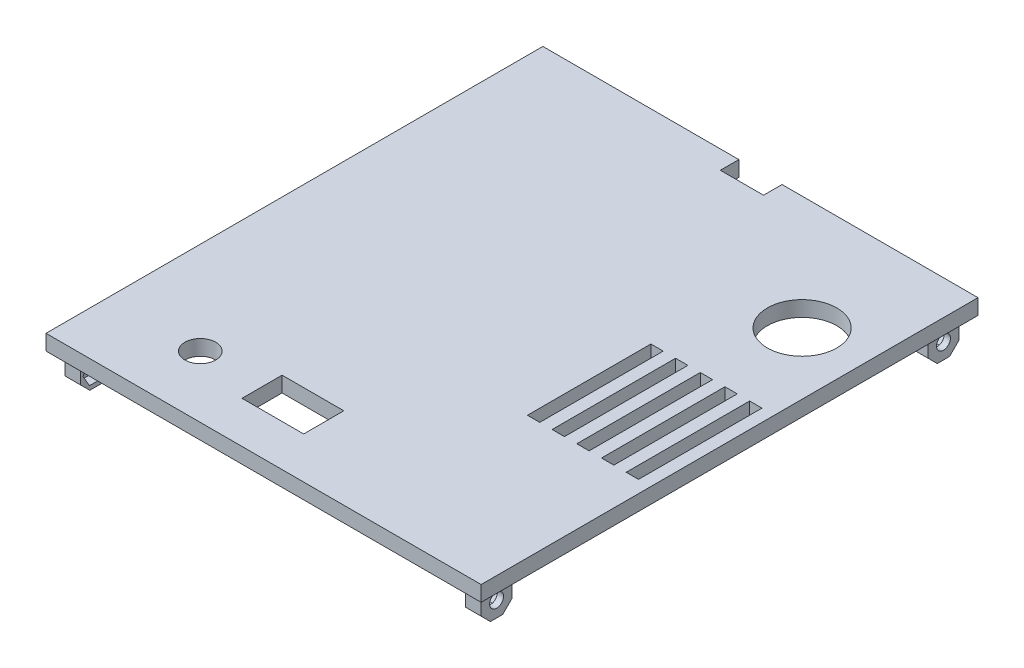
from build123d import *

# Parameters (mm, degrees)
SKETCH1_W                      = 141
SKETCH1_H                      = 161
BOSS_EXTRUDE1_DEPTH            = 5
CUT_EXTRUDE1_REACH             = 7
SKETCH2_R                      = 11.25
CUT_EXTRUDE1_DIRECTION_2_DEPTH = 1
CUT_EXTRUDE2_REACH             = 7
SKETCH3_W                      = 4
SKETCH3_H                      = 40
SKETCH4_W                      = 5
SKETCH4_H                      = 10
BOSS_EXTRUDE2_DEPTH            = 10
SKETCH5_R                      = 2.25
CUT_EXTRUDE3_DEPTH             = 4.1
CUT_EXTRUDE3_DEPTH_BACK        = 138.9
CUT_EXTRUDE4_DEPTH             = 3
CHAMFER1_SIZE                  = 3
MIRROR4_COPY_1_DEPTH           = 3
CUT_EXTRUDE5_REACH             = 17
SKETCH7_R                      = 5
SKETCH7_W                      = 20
SKETCH7_H                      = 13
CUT_EXTRUDE5_DIRECTION_2_DEPTH = 1
SKETCH8_W                      = 3.5
SKETCH8_H                      = 1
CUT_EXTRUDE6_DEPTH             = 11
CUT_EXTRUDE6_DEPTH_BACK        = 4
CUT_EXTRUDE7_REACH             = 17
SKETCH9_W                      = 14
SKETCH9_H                      = 6
CUT_EXTRUDE7_DIRECTION_2_DEPTH = 1


with BuildPart() as part:
    # Sketch1 → Boss-Extrude1 (new body)
    with BuildSketch(Plane(origin=(0, 0, 0), x_dir=(1, 0, 0), z_dir=(0, 1, 0))):
        Rectangle(SKETCH1_W, SKETCH1_H)
    extrude(amount=BOSS_EXTRUDE1_DEPTH)

    # Sketch2 → Cut-Extrude1 (cut, up to next)
    with BuildSketch(Plane(origin=(0, 5, 0), x_dir=(1, 0, 0), z_dir=(0, 1, 0)), mode=Mode.PRIVATE) as cut_extrude1_sk1:
        with Locations((50.5, 43.5)):
            Circle(SKETCH2_R)
    cut_extrude1_tool1 = extrude(cut_extrude1_sk1.sketch, amount=-CUT_EXTRUDE1_REACH, mode=Mode.PRIVATE) & part.part
    add(cut_extrude1_tool1.solids().sort_by_distance((50.5, 5, -43.5))[0], mode=Mode.SUBTRACT)

    # Sketch2 → Cut-Extrude1 direction 2 (cut)
    with BuildSketch(Plane(origin=(0, 5, 0), x_dir=(1, 0, 0), z_dir=(0, 1, 0))):
        with Locations((50.5, 43.5)):
            Circle(SKETCH2_R)
    extrude(amount=CUT_EXTRUDE1_DIRECTION_2_DEPTH, mode=Mode.SUBTRACT)

    # Sketch3 → Cut-Extrude2 (cut, up to next)
    with BuildSketch(Plane(origin=(0, 5, 0), x_dir=(1, 0, 0), z_dir=(0, 1, 0)), mode=Mode.PRIVATE) as cut_extrude2_sk1:
        with Locations((40.5, -5.5)):
            Rectangle(SKETCH3_W, SKETCH3_H)
    cut_extrude2_tool1 = extrude(cut_extrude2_sk1.sketch, amount=-CUT_EXTRUDE2_REACH, mode=Mode.PRIVATE) & part.part
    add(cut_extrude2_tool1.solids().sort_by_distance((40.5, 5, 5.5))[0], mode=Mode.SUBTRACT)
    # Sketch3 → Cut-Extrude2 (cut, up to next)
    with BuildSketch(Plane(origin=(0, 5, 0), x_dir=(1, 0, 0), z_dir=(0, 1, 0)), mode=Mode.PRIVATE) as cut_extrude2_sk2:
        with Locations((32.5, -5.5)):
            Rectangle(SKETCH3_W, SKETCH3_H)
    cut_extrude2_tool2 = extrude(cut_extrude2_sk2.sketch, amount=-CUT_EXTRUDE2_REACH, mode=Mode.PRIVATE) & part.part
    add(cut_extrude2_tool2.solids().sort_by_distance((32.5, 5, 5.5))[0], mode=Mode.SUBTRACT)
    # Sketch3 → Cut-Extrude2 (cut, up to next)
    with BuildSketch(Plane(origin=(0, 5, 0), x_dir=(1, 0, 0), z_dir=(0, 1, 0)), mode=Mode.PRIVATE) as cut_extrude2_sk3:
        with Locations((48.5, -5.5)):
            Rectangle(SKETCH3_W, SKETCH3_H)
    cut_extrude2_tool3 = extrude(cut_extrude2_sk3.sketch, amount=-CUT_EXTRUDE2_REACH, mode=Mode.PRIVATE) & part.part
    add(cut_extrude2_tool3.solids().sort_by_distance((48.5, 5, 5.5))[0], mode=Mode.SUBTRACT)
    # Sketch3 → Cut-Extrude2 (cut, up to next)
    with BuildSketch(Plane(origin=(0, 5, 0), x_dir=(1, 0, 0), z_dir=(0, 1, 0)), mode=Mode.PRIVATE) as cut_extrude2_sk4:
        with Locations((56.5, -5.5)):
            Rectangle(SKETCH3_W, SKETCH3_H)
    cut_extrude2_tool4 = extrude(cut_extrude2_sk4.sketch, amount=-CUT_EXTRUDE2_REACH, mode=Mode.PRIVATE) & part.part
    add(cut_extrude2_tool4.solids().sort_by_distance((56.5, 5, 5.5))[0], mode=Mode.SUBTRACT)
    # Sketch3 → Cut-Extrude2 (cut, up to next)
    with BuildSketch(Plane(origin=(0, 5, 0), x_dir=(1, 0, 0), z_dir=(0, 1, 0)), mode=Mode.PRIVATE) as cut_extrude2_sk5:
        with Locations((64.5, -5.5)):
            Rectangle(SKETCH3_W, SKETCH3_H)
    cut_extrude2_tool5 = extrude(cut_extrude2_sk5.sketch, amount=-CUT_EXTRUDE2_REACH, mode=Mode.PRIVATE) & part.part
    add(cut_extrude2_tool5.solids().sort_by_distance((64.5, 5, 5.5))[0], mode=Mode.SUBTRACT)

    # Sketch4 → Boss-Extrude2 (add)
    with BuildSketch(Plane.XZ):
        with Locations((64.9, 72.4)):
            Rectangle(SKETCH4_W, SKETCH4_H)
        with Locations((-64.9, 72.4)):
            Rectangle(SKETCH4_W, SKETCH4_H)
        with Locations((64.9, -72.4)):
            Rectangle(SKETCH4_W, SKETCH4_H)
        with Locations((-64.9, -72.4)):
            Rectangle(SKETCH4_W, SKETCH4_H)
    extrude(amount=BOSS_EXTRUDE2_DEPTH)

    # Sketch5 → Cut-Extrude3 (cut, two sides)
    with BuildSketch(Plane(origin=(67.4, 0, 0), x_dir=(0, 0, -1), z_dir=(1, 0, 0))) as cut_extrude3_sk:
        with Locations((-72.4, -5)):
            Circle(SKETCH5_R)
        with Locations((72.4, -5)):
            Circle(SKETCH5_R)
    extrude(amount=CUT_EXTRUDE3_DEPTH, mode=Mode.SUBTRACT)
    extrude(cut_extrude3_sk.sketch, amount=-CUT_EXTRUDE3_DEPTH_BACK, mode=Mode.SUBTRACT)

    # Sketch6 → Cut-Extrude4 (cut)
    with BuildSketch(Plane(origin=(-62.4, 0, 0), x_dir=(0, 0, -1), z_dir=(1, 0, 0))):
        Polygon((-68.185343035, -5), (-70.292671517, -1.35), (-74.507328483, -1.35), (-76.614656965, -5), (-74.507328483, -8.65), (-70.292671517, -8.65), align=None)
    cut_extrude4 = extrude(amount=-CUT_EXTRUDE4_DEPTH, mode=Mode.SUBTRACT)

    # Chamfer1
    chamfer1_edges = [part.edges().sort_by_distance(p)[0] for p in [
        (-64.9, -10, 77.4),
        (-64.9, -10, 67.4),
        (64.9, -10, -77.4),
        (64.9, -10, -67.4),
        (-64.9, -10, -77.4),
        (-64.9, -10, -67.4),
        (64.9, -10, 67.4),
        (64.9, -10, 77.4),
    ]]
    chamfer(chamfer1_edges, length=CHAMFER1_SIZE)

    # Mirror3: Cut-Extrude4 across plane
    add(cut_extrude4.mirror(Plane(origin=(0, 0, 0), x_dir=(0, 0, 1), z_dir=(1, 0, 0))), mode=Mode.SUBTRACT)

    # Mirror4: Cut-Extrude4 across plane
    add(cut_extrude4.mirror(Plane.XY), mode=Mode.SUBTRACT)

    # Mirror4 copy 1 sketch → Mirror4 copy 1 (cut)
    with BuildSketch(Plane.ZY.offset(-62.4)):
        Polygon((-68.185343035, -5), (-70.292671517, -1.35), (-74.507328483, -1.35), (-76.614656965, -5), (-74.507328483, -8.65), (-70.292671517, -8.65), align=None)
    extrude(amount=-MIRROR4_COPY_1_DEPTH, mode=Mode.SUBTRACT)

    # Sketch7 → Cut-Extrude5 (cut, up to next)
    with BuildSketch(Plane(origin=(0, 5, 0), x_dir=(1, 0, 0), z_dir=(0, 1, 0)), mode=Mode.PRIVATE) as cut_extrude5_sk1:
        with Locations((-40.5, -60.5)):
            Circle(SKETCH7_R)
    cut_extrude5_tool1 = extrude(cut_extrude5_sk1.sketch, amount=-CUT_EXTRUDE5_REACH, mode=Mode.PRIVATE) & part.part
    add(cut_extrude5_tool1.solids().sort_by_distance((-40.5, 5, 60.5))[0], mode=Mode.SUBTRACT)
    # Sketch7 → Cut-Extrude5 (cut, up to next)
    with BuildSketch(Plane(origin=(0, 5, 0), x_dir=(1, 0, 0), z_dir=(0, 1, 0)), mode=Mode.PRIVATE) as cut_extrude5_sk2:
        with Locations((-10.5, -60.5)):
            Rectangle(SKETCH7_W, SKETCH7_H)
    cut_extrude5_tool2 = extrude(cut_extrude5_sk2.sketch, amount=-CUT_EXTRUDE5_REACH, mode=Mode.PRIVATE) & part.part
    add(cut_extrude5_tool2.solids().sort_by_distance((-10.5, 5, 60.5))[0], mode=Mode.SUBTRACT)

    # Sketch7 → Cut-Extrude5 direction 2 (cut)
    with BuildSketch(Plane(origin=(0, 5, 0), x_dir=(1, 0, 0), z_dir=(0, 1, 0))):
        with Locations((-40.5, -60.5)):
            Circle(SKETCH7_R)
        with Locations((-10.5, -60.5)):
            Rectangle(SKETCH7_W, SKETCH7_H)
    extrude(amount=CUT_EXTRUDE5_DIRECTION_2_DEPTH, mode=Mode.SUBTRACT)

    # Sketch8 → Cut-Extrude6 (cut, two sides)
    with BuildSketch(Plane.XZ) as cut_extrude6_sk:
        with Locations((-40.5, 74)):
            Rectangle(SKETCH8_W, SKETCH8_H)
        with Locations((-40.5, 47)):
            Rectangle(SKETCH8_W, SKETCH8_H)
    extrude(amount=CUT_EXTRUDE6_DEPTH, mode=Mode.SUBTRACT)
    extrude(cut_extrude6_sk.sketch, amount=-CUT_EXTRUDE6_DEPTH_BACK, mode=Mode.SUBTRACT)

    # Sketch9 → Cut-Extrude7 (cut, up to next)
    with BuildSketch(Plane(origin=(0, 5, 0), x_dir=(1, 0, 0), z_dir=(0, 1, 0)), mode=Mode.PRIVATE) as cut_extrude7_sk1:
        with Locations((0, 77.5)):
            Rectangle(SKETCH9_W, SKETCH9_H)
    cut_extrude7_tool1 = extrude(cut_extrude7_sk1.sketch, amount=-CUT_EXTRUDE7_REACH, mode=Mode.PRIVATE) & part.part
    add(cut_extrude7_tool1.solids().sort_by_distance((0, 5, -77.5))[0], mode=Mode.SUBTRACT)

    # Sketch9 → Cut-Extrude7 direction 2 (cut)
    with BuildSketch(Plane(origin=(0, 5, 0), x_dir=(1, 0, 0), z_dir=(0, 1, 0))):
        with Locations((0, 77.5)):
            Rectangle(SKETCH9_W, SKETCH9_H)
    extrude(amount=CUT_EXTRUDE7_DIRECTION_2_DEPTH, mode=Mode.SUBTRACT)


solid = part.part
